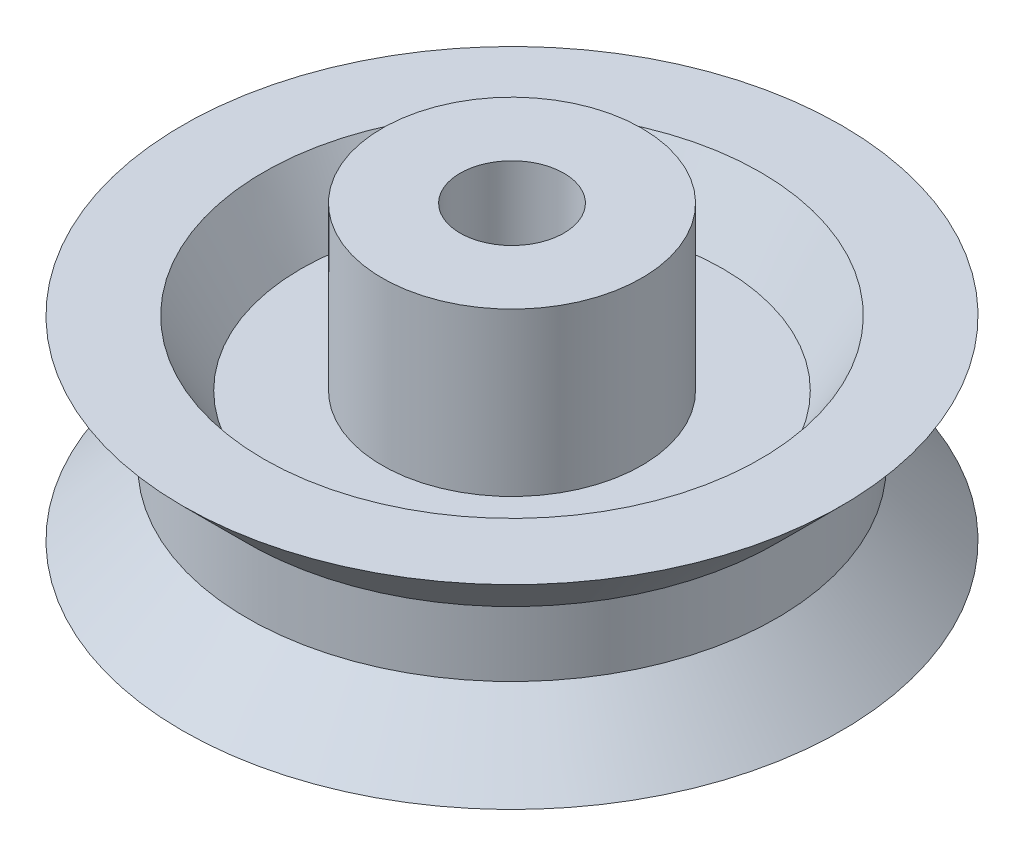
from build123d import *


with BuildPart() as part:
    # Esquisse2 → Révolution1 (revolve)
    with BuildSketch(Plane(origin=(0, 0, 0), x_dir=(0, 0, -1), z_dir=(1, 0, 0))):
        Polygon((4, 0), (4, -5), (1.6, -5), (1.6, 7), (4, 7), (4, 2), (6.5, 2), (7.654700538, 4), (10.154700538, 4), (8.154700538, 2), (8.154700538, 0), (10.154700538, -2), (7.654700538, -2), (6.5, 0), align=None)
    revolve(axis=Axis((0, 0, 0), (0, 1, 0)))


solid = part.part
